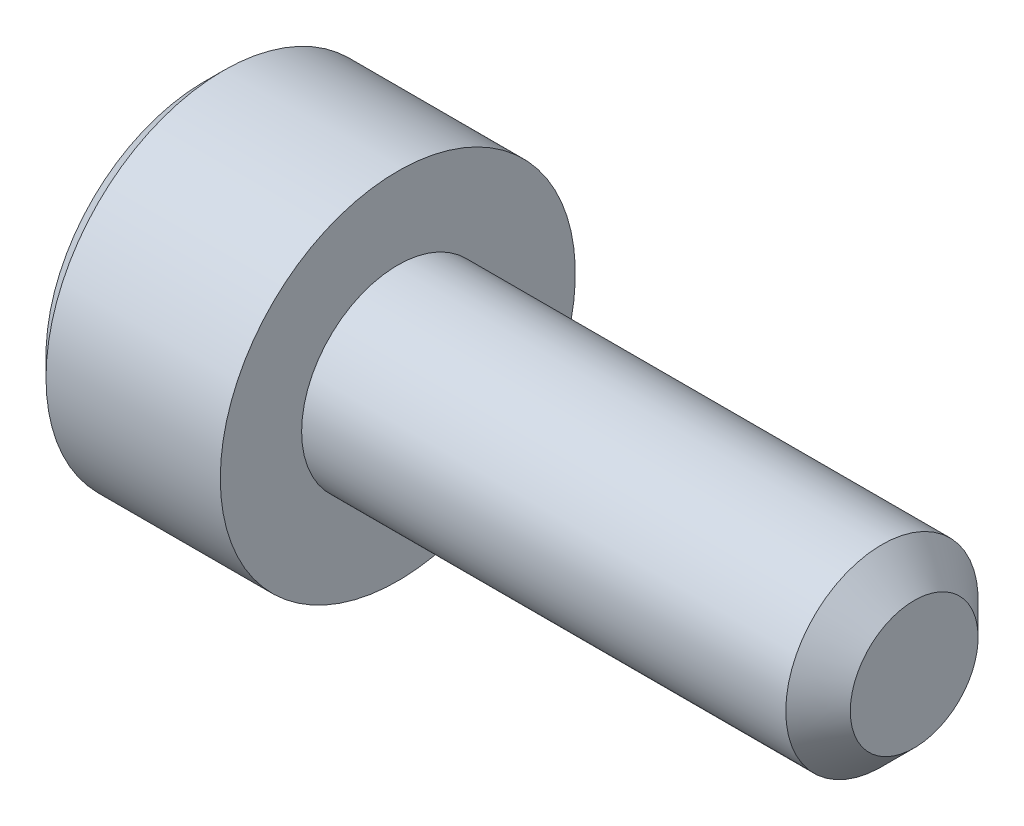
from build123d import *

# Parameters (mm, degrees)
CHAMFER1_SIZE      = 0.5
CHAMFER2_SIZE      = 0.3
CUT_EXTRUDE1_DEPTH = 2.5
CHAMFER3_SIZE      = 0.3


with BuildPart() as part:
    # Sketch1 → Revolve1 (revolve)
    with BuildSketch(Plane.XY):
        Polygon((0, 0), (0, 2.75), (3, 2.75), (3, 1.49), (11, 1.49), (11, 0), align=None)
    revolve(axis=Axis((-88.705490849, 0, 0), (1, 0, 0)))

    # Chamfer1
    chamfer1_edges = [part.edges().sort_by_distance(p)[0] for p in [
        (11, -1.49, 0),
    ]]
    chamfer(chamfer1_edges, length=CHAMFER1_SIZE)

    # Chamfer2
    chamfer2_edges = [part.edges().sort_by_distance(p)[0] for p in [
        (0, -2.75, 0),
    ]]
    chamfer(chamfer2_edges, length=CHAMFER2_SIZE)

    # Sketch3 → Cut-Extrude1 (cut)
    with BuildSketch(Plane(origin=(0, 0, 0), x_dir=(0, 0, -1), z_dir=(1, 0, 0))):
        Polygon((-1.443375673, 0), (-0.721687836, -1.25), (0.721687836, -1.25), (1.443375673, 0), (0.721687836, 1.25), (-0.721687836, 1.25), align=None)
    extrude(amount=CUT_EXTRUDE1_DEPTH, mode=Mode.SUBTRACT)

    # Chamfer3
    chamfer3_edges = [part.edges().sort_by_distance(p)[0] for p in [
        (0, 1.25, 0),
        (0, 0.625, 1.082531755),
        (0, -0.625, 1.082531755),
        (0, -1.25, 0),
        (0, -0.625, -1.082531755),
        (0, 0.625, -1.082531755),
    ]]
    chamfer(chamfer3_edges, length=CHAMFER3_SIZE)


solid = part.part
